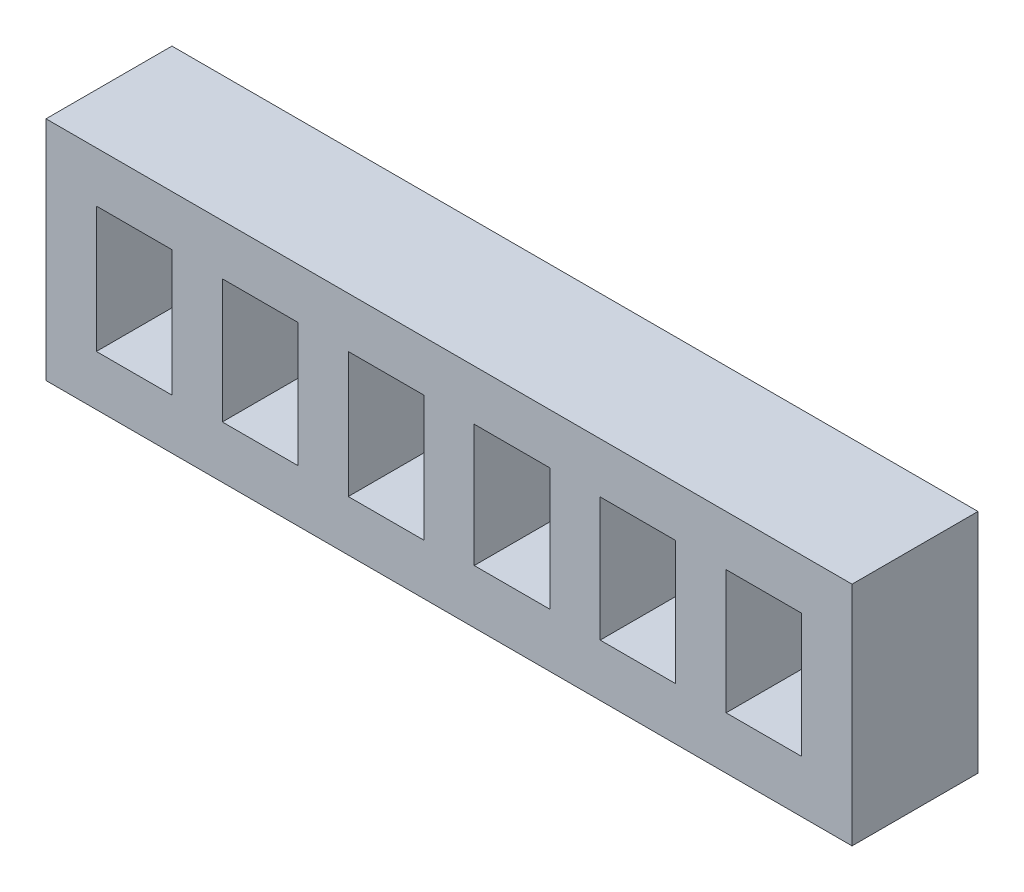
from build123d import *

# Parameters (mm, degrees)
SKETCH3_W           = 32
SKETCH3_H           = 9
SKETCH3_W_2         = 3
SKETCH3_H_2         = 4.92374822
SKETCH3_H_3         = 5
SKETCH3_H_4         = 4.987531068
SKETCH3_H_5         = 4.859965372
BOSS_EXTRUDE1_DEPTH = 5


with BuildPart() as part:
    # Sketch3 → Boss-Extrude1 (new body)
    with BuildSketch(Plane.XY):
        with Locations((-17.451761754, 7.150515716)):
            Rectangle(SKETCH3_W, SKETCH3_H)
        with Locations((-24.951761754, 7.188641606)):
            Rectangle(SKETCH3_W_2, SKETCH3_H_2, mode=Mode.SUBTRACT)
        with Locations((-29.951761754, 7.150515716)):
            Rectangle(SKETCH3_W_2, SKETCH3_H_3, mode=Mode.SUBTRACT)
        with Locations((-19.951761754, 7.156750182)):
            Rectangle(SKETCH3_W_2, SKETCH3_H_4, mode=Mode.SUBTRACT)
        with Locations((-14.951761754, 7.22053303)):
            Rectangle(SKETCH3_W_2, SKETCH3_H_5, mode=Mode.SUBTRACT)
        with Locations((-9.951761754, 7.188641606)):
            Rectangle(SKETCH3_W_2, SKETCH3_H_2, mode=Mode.SUBTRACT)
        with Locations((-4.951761754, 7.188641606)):
            Rectangle(SKETCH3_W_2, SKETCH3_H_2, mode=Mode.SUBTRACT)
    extrude(amount=BOSS_EXTRUDE1_DEPTH)


solid = part.part
